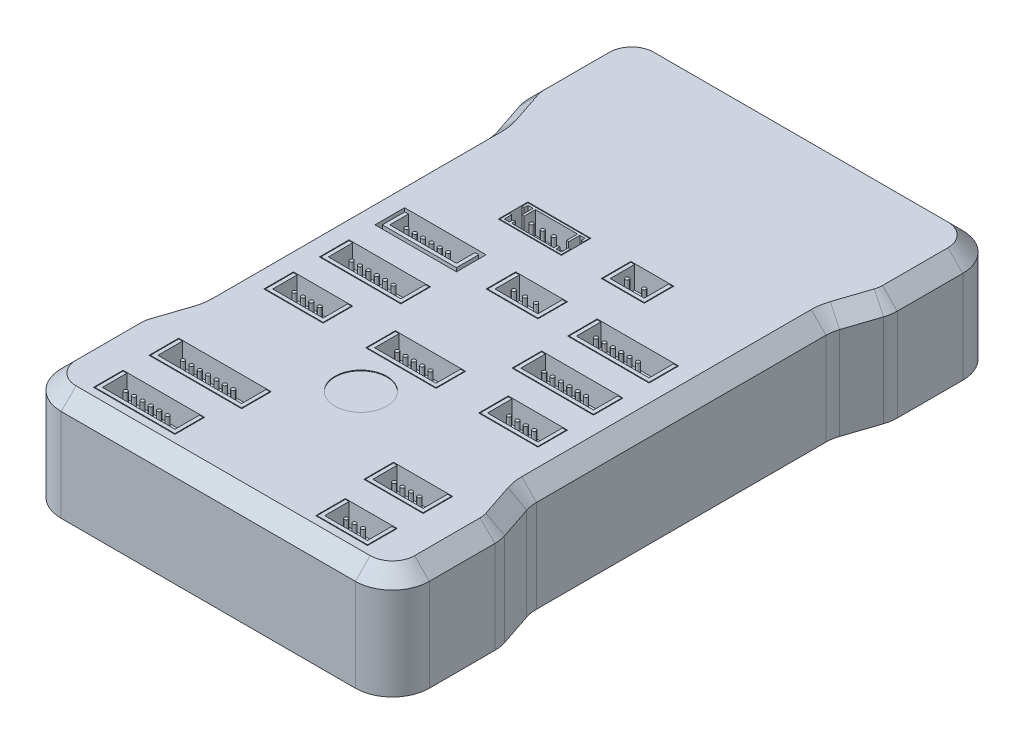
from build123d import *

# Parameters (mm, degrees)
BOSS_EXTRUDE1_DEPTH  = 16
CHAMFER2_SIZE        = 2
CHAMFER3_SIZE        = 3.5
CHAMFER3_SIZE2       = 1.5
CUT_EXTRUDE2_DEPTH   = 0.5
SKETCH5_W            = 8.5
SKETCH5_H            = 4
SKETCH5_W_2          = 5.8
SKETCH5_W_3          = 11
SKETCH5_W_4          = 7
SKETCH5_W_5          = 8
SKETCH5_W_6          = 9.5
SKETCH5_W_7          = 12.5
CUT_EXTRUDE3_DEPTH   = 4
BOSS_EXTRUDE2_DEPTH  = 4
SKETCH7_W            = 8.3
SKETCH7_H            = 3.8
BOSS_EXTRUDE3_DEPTH  = 1
SKETCH8_R            = 0.25
BOSS_EXTRUDE4_DEPTH  = 3
BOSS_EXTRUDE5_DEPTH  = 4
BOSS_EXTRUDE6_DEPTH  = 1
SKETCH11_R           = 0.25
BOSS_EXTRUDE7_DEPTH  = 3
SKETCH12_W           = 10
SKETCH12_H           = 3
BOSS_EXTRUDE8_DEPTH  = 1
BOSS_EXTRUDE9_DEPTH  = 3
SKETCH14_R           = 0.25
BOSS_EXTRUDE10_DEPTH = 3
SKETCH15_W           = 6.8
SKETCH15_H           = 3.8
BOSS_EXTRUDE11_DEPTH = 1
BOSS_EXTRUDE12_DEPTH = 3
SKETCH17_R           = 0.25
BOSS_EXTRUDE13_DEPTH = 3
SKETCH18_W           = 10.8
SKETCH18_H           = 3.8
BOSS_EXTRUDE14_DEPTH = 1
BOSS_EXTRUDE15_DEPTH = 3
SKETCH20_R           = 0.25
SKETCH20_R_2         = 0.247012806
SKETCH20_R_3         = 0.247012796
BOSS_EXTRUDE16_DEPTH = 3
SKETCH22_W           = 10.8
SKETCH22_H           = 3.8
BOSS_EXTRUDE17_DEPTH = 1
BOSS_EXTRUDE18_DEPTH = 3
SKETCH24_R           = 0.25
BOSS_EXTRUDE19_DEPTH = 3
SKETCH25_W           = 10.8
SKETCH25_H           = 3.8
BOSS_EXTRUDE20_DEPTH = 1
BOSS_EXTRUDE21_DEPTH = 3
SKETCH27_R           = 0.25
BOSS_EXTRUDE22_DEPTH = 3
SKETCH28_W           = 7.8
SKETCH28_H           = 3.8
BOSS_EXTRUDE23_DEPTH = 1
BOSS_EXTRUDE24_DEPTH = 3
SKETCH30_R           = 0.25
BOSS_EXTRUDE25_DEPTH = 3
SKETCH31_W           = 9.3
SKETCH31_H           = 3.8
BOSS_EXTRUDE26_DEPTH = 1
BOSS_EXTRUDE27_DEPTH = 3
SKETCH33_R           = 0.25
BOSS_EXTRUDE28_DEPTH = 3
SKETCH34_W           = 7.8
SKETCH34_H           = 3.8
BOSS_EXTRUDE29_DEPTH = 1
BOSS_EXTRUDE30_DEPTH = 3
SKETCH36_R           = 0.25
BOSS_EXTRUDE31_DEPTH = 3
SKETCH37_W           = 12.3
SKETCH37_H           = 3.8
BOSS_EXTRUDE32_DEPTH = 1
BOSS_EXTRUDE33_DEPTH = 3
SKETCH39_R           = 0.25
BOSS_EXTRUDE34_DEPTH = 3
SKETCH40_W           = 7.8
SKETCH40_H           = 3.8
BOSS_EXTRUDE35_DEPTH = 1
BOSS_EXTRUDE36_DEPTH = 3
SKETCH42_R           = 0.25
BOSS_EXTRUDE37_DEPTH = 3
SKETCH43_W           = 10.8
SKETCH43_H           = 3.8
BOSS_EXTRUDE38_DEPTH = 1
BOSS_EXTRUDE39_DEPTH = 3
SKETCH45_R           = 0.25
BOSS_EXTRUDE40_DEPTH = 3
SKETCH46_W           = 6.8
SKETCH46_H           = 3.8
BOSS_EXTRUDE41_DEPTH = 1
BOSS_EXTRUDE42_DEPTH = 3
SKETCH48_R           = 0.25
BOSS_EXTRUDE43_DEPTH = 3
SKETCH49_R           = 3.5
CUT_EXTRUDE4_DEPTH   = 0.1
SKETCH51_W           = 39.7
SKETCH51_H           = 9
CUT_EXTRUDE5_DEPTH   = 7
SKETCH52_R           = 0.25
BOSS_EXTRUDE46_DEPTH = 7


with BuildPart() as part:
    # Sketch1 → Boss-Extrude1 (new body)
    with BuildSketch(Plane(origin=(0, 0, 0), x_dir=(1, 0, 0), z_dir=(0, 1, 0))):
        with BuildLine():
            Line((-19.85, 41), (19.85, 41))
            ThreePointArc((19.85, 41), (23.385533906, 39.535533906), (24.85, 36))
            Line((24.85, 36), (24.85, 27.161388301))
            ThreePointArc((24.85, 27.161388301), (24.785437288, 26.360477086), (24.59341649, 25.580249471))
            Line((24.59341649, 25.580249471), (23.10658351, 21.119750529))
            ThreePointArc((23.10658351, 21.119750529), (22.914562712, 20.339522914), (22.85, 19.538611699))
            Line((22.85, 19.538611699), (22.85, -19.538611699))
            ThreePointArc((22.85, -19.538611699), (22.914562712, -20.339522914), (23.10658351, -21.119750529))
            Line((23.10658351, -21.119750529), (24.59341649, -25.580249471))
            ThreePointArc((24.59341649, -25.580249471), (24.785437288, -26.360477086), (24.85, -27.161388301))
            Line((24.85, -27.161388301), (24.85, -36))
            ThreePointArc((24.85, -36), (23.385533906, -39.535533906), (19.85, -41))
            Line((19.85, -41), (-19.85, -41))
            ThreePointArc((-19.85, -41), (-23.385533906, -39.535533906), (-24.85, -36))
            Line((-24.85, -36), (-24.85, -27.161388301))
            ThreePointArc((-24.85, -27.161388301), (-24.785437288, -26.360477086), (-24.59341649, -25.580249471))
            Line((-24.59341649, -25.580249471), (-23.10658351, -21.119750529))
            ThreePointArc((-23.10658351, -21.119750529), (-22.914562712, -20.339522914), (-22.85, -19.538611699))
            Line((-22.85, -19.538611699), (-22.85, 19.538611699))
            ThreePointArc((-22.85, 19.538611699), (-22.914562712, 20.339522914), (-23.10658351, 21.119750529))
            Line((-23.10658351, 21.119750529), (-24.59341649, 25.580249471))
            ThreePointArc((-24.59341649, 25.580249471), (-24.785437288, 26.360477086), (-24.85, 27.161388301))
            Line((-24.85, 27.161388301), (-24.85, 36))
            ThreePointArc((-24.85, 36), (-23.385533906, 39.535533906), (-19.85, 41))
        make_face()
    extrude(amount=BOSS_EXTRUDE1_DEPTH)

    # Chamfer2
    chamfer2_edges = [part.edges().sort_by_distance(p)[0] for p in [
        (22.914562712, 16, 20.339522914),
        (22.85, 16, 0),
        (23.85, 16, 23.35),
        (22.914562712, 16, -20.339522914),
        (24.785437288, 16, 26.360477086),
        (23.85, 16, -23.35),
        (24.85, 16, 31.58069415),
        (24.785437288, 16, -26.360477086),
        (23.385533906, 16, 39.535533906),
        (24.85, 16, -31.58069415),
        (0, 16, 41),
        (23.385533906, 16, -39.535533906),
        (-23.385533906, 16, 39.535533906),
        (0, 16, -41),
        (-24.85, 16, 31.58069415),
        (-23.385533906, 16, -39.535533906),
        (-24.785437288, 16, 26.360477086),
        (-24.85, 16, -31.58069415),
        (-23.85, 16, 23.35),
        (-24.785437288, 16, -26.360477086),
        (-22.914562712, 16, 20.339522914),
        (-23.85, 16, -23.35),
        (-22.85, 16, 0),
        (-22.914562712, 16, -20.339522914),
    ]]
    chamfer(chamfer2_edges, length=CHAMFER2_SIZE)

    # Chamfer3
    chamfer3_edges = [part.edges().sort_by_distance(p)[0] for p in [
        (24.85, 0, -31.58069415),
        (24.785437288, 0, -26.360477086),
        (23.85, 0, -23.35),
        (22.914562712, 0, -20.339522914),
        (22.85, 0, 0),
        (22.914562712, 0, 20.339522914),
        (23.85, 0, 23.35),
        (24.785437288, 0, 26.360477086),
        (24.85, 0, 31.58069415),
        (23.385533906, 0, 39.535533906),
        (0, 0, 41),
        (-23.385533906, 0, 39.535533906),
        (-24.85, 0, 31.58069415),
        (-24.785437288, 0, 26.360477086),
        (-23.85, 0, 23.35),
        (-22.914562712, 0, 20.339522914),
        (-22.85, 0, 0),
        (-22.914562712, 0, -20.339522914),
        (-23.85, 0, -23.35),
        (-24.785437288, 0, -26.360477086),
        (-24.85, 0, -31.58069415),
        (-23.385533906, 0, -39.535533906),
        (0, 0, -41),
        (23.385533906, 0, -39.535533906),
    ]]
    chamfer3_side = [part.faces().sort_by_distance(p)[0] for p in [
        (0, 0, 0),
    ]]
    chamfer(chamfer3_edges, length=CHAMFER3_SIZE, length2=CHAMFER3_SIZE2, reference=chamfer3_side[0])

    # Sketch4 → Cut-Extrude2 (cut)
    with BuildSketch(Plane.XZ):
        with BuildLine():
            Line((-18.35, 36.5), (-12.35, 36.5))
            ThreePointArc((-12.35, 36.5), (-10.935786438, 35.914213562), (-10.35, 34.5))
            Line((-10.35, 34.5), (-10.35, 28.5))
            ThreePointArc((-10.35, 28.5), (-10.935786438, 27.085786438), (-12.35, 26.5))
            Line((-12.35, 26.5), (-18.35, 26.5))
            ThreePointArc((-18.35, 26.5), (-19.764213562, 27.085786438), (-20.35, 28.5))
            Line((-20.35, 28.5), (-20.35, 34.5))
            ThreePointArc((-20.35, 34.5), (-19.764213562, 35.914213562), (-18.35, 36.5))
        make_face()
        with BuildLine():
            Line((18.35, 26.5), (12.35, 26.5))
            ThreePointArc((12.35, 26.5), (10.935786438, 27.085786438), (10.35, 28.5))
            Line((10.35, 28.5), (10.35, 34.5))
            ThreePointArc((10.35, 34.5), (10.935786438, 35.914213562), (12.35, 36.5))
            Line((12.35, 36.5), (18.35, 36.5))
            ThreePointArc((18.35, 36.5), (19.764213562, 35.914213562), (20.35, 34.5))
            Line((20.35, 34.5), (20.35, 28.5))
            ThreePointArc((20.35, 28.5), (19.764213562, 27.085786438), (18.35, 26.5))
        make_face()
        with BuildLine():
            Line((20.35, -34.5), (20.35, -28.5))
            ThreePointArc((20.35, -28.5), (19.764213562, -27.085786438), (18.35, -26.5))
            Line((18.35, -26.5), (12.35, -26.5))
            ThreePointArc((12.35, -26.5), (10.935786438, -27.085786438), (10.35, -28.5))
            Line((10.35, -28.5), (10.35, -34.5))
            ThreePointArc((10.35, -34.5), (10.935786438, -35.914213562), (12.35, -36.5))
            Line((12.35, -36.5), (18.35, -36.5))
            ThreePointArc((18.35, -36.5), (19.764213562, -35.914213562), (20.35, -34.5))
        make_face()
        with BuildLine():
            Line((-18.35, -26.5), (-12.35, -26.5))
            ThreePointArc((-12.35, -26.5), (-10.935786438, -27.085786438), (-10.35, -28.5))
            Line((-10.35, -28.5), (-10.35, -34.5))
            ThreePointArc((-10.35, -34.5), (-10.935786438, -35.914213562), (-12.35, -36.5))
            Line((-12.35, -36.5), (-18.35, -36.5))
            ThreePointArc((-18.35, -36.5), (-19.764213562, -35.914213562), (-20.35, -34.5))
            Line((-20.35, -34.5), (-20.35, -28.5))
            ThreePointArc((-20.35, -28.5), (-19.764213562, -27.085786438), (-18.35, -26.5))
        make_face()
        with BuildLine():
            Line((-10.75, 17.75), (10.75, 17.75))
            ThreePointArc((10.75, 17.75), (12.164213562, 17.164213562), (12.75, 15.75))
            Line((12.75, 15.75), (12.75, -15.75))
            ThreePointArc((12.75, -15.75), (12.164213562, -17.164213562), (10.75, -17.75))
            Line((10.75, -17.75), (-10.75, -17.75))
            ThreePointArc((-10.75, -17.75), (-12.164213562, -17.164213562), (-12.75, -15.75))
            Line((-12.75, -15.75), (-12.75, 15.75))
            ThreePointArc((-12.75, 15.75), (-12.164213562, 17.164213562), (-10.75, 17.75))
        make_face()
    extrude(amount=-CUT_EXTRUDE2_DEPTH, mode=Mode.SUBTRACT)

    # Sketch5 → Cut-Extrude3 (cut)
    with BuildSketch(Plane(origin=(0, 16, 0), x_dir=(1, 0, 0), z_dir=(0, 1, 0))):
        with Locations((-6.6, 11)):
            Rectangle(SKETCH5_W, SKETCH5_H)
        with Locations((5.95, 11)):
            Rectangle(SKETCH5_W_2, SKETCH5_H)
        with Locations((-13, -5.5)):
            Rectangle(SKETCH5_W_3, SKETCH5_H)
        with Locations((-13, 2)):
            Rectangle(SKETCH5_W_3, SKETCH5_H)
        with Locations((0, 2)):
            Rectangle(SKETCH5_W_4, SKETCH5_H)
        with Locations((13, 2)):
            Rectangle(SKETCH5_W_3, SKETCH5_H)
        with Locations((13, -5.5)):
            Rectangle(SKETCH5_W_3, SKETCH5_H)
        with Locations((-14.5, -13)):
            Rectangle(SKETCH5_W_5, SKETCH5_H)
        with Locations((0, -13)):
            Rectangle(SKETCH5_W_6, SKETCH5_H)
        with Locations((14.5, -13)):
            Rectangle(SKETCH5_W_5, SKETCH5_H)
        with Locations((-13, -36)):
            Rectangle(SKETCH5_W_3, SKETCH5_H)
        with Locations((-12.25, -28.5)):
            Rectangle(SKETCH5_W_7, SKETCH5_H)
        with Locations((14.5, -28.5)):
            Rectangle(SKETCH5_W_5, SKETCH5_H)
        with Locations((15, -36)):
            Rectangle(SKETCH5_W_4, SKETCH5_H)
    extrude(amount=-CUT_EXTRUDE3_DEPTH, mode=Mode.SUBTRACT)

    # Sketch6 → Boss-Extrude2 (add)
    with BuildSketch(Plane(origin=(0, 12, 0), x_dir=(1, 0, 0), z_dir=(0, 1, 0))):
        Polygon((-9.75, 11.1), (-9.45, 11.1), (-9.45, 12.6), (-3.75, 12.6), (-3.75, 11.1), (-3.45, 11.1), (-3.45, 12.6), (-2.75, 12.6), (-2.75, 12.1), (-2.45, 12.1), (-2.45, 12.9), (-10.75, 12.9), (-10.75, 12.1), (-10.45, 12.1), (-10.45, 12.6), (-9.75, 12.6), align=None)
        Polygon((-3.45, 9.4), (-2.75, 9.4), (-2.75, 10.4), (-2.45, 10.4), (-2.45, 9.1), (-10.75, 9.1), (-10.75, 10.4), (-10.45, 10.4), (-10.45, 9.4), (-9.75, 9.4), (-9.75, 9.9), (-9.45, 9.9), (-9.45, 9.4), (-3.75, 9.4), (-3.75, 9.9), (-3.45, 9.9), align=None)
    extrude(amount=BOSS_EXTRUDE2_DEPTH)

    # Sketch7 → Boss-Extrude3 (add)
    with BuildSketch(Plane(origin=(0, 12, 0), x_dir=(1, 0, 0), z_dir=(0, 1, 0))):
        with Locations((-6.6, 11)):
            Rectangle(SKETCH7_W, SKETCH7_H)
    extrude(amount=BOSS_EXTRUDE3_DEPTH)

    # Sketch8 → Boss-Extrude4 (add)
    with BuildSketch(Plane(origin=(0, 13, 0), x_dir=(1, 0, 0), z_dir=(0, 1, 0))):
        with Locations((-6.6, 10.75)):
            Circle(SKETCH8_R)
        with Locations((-5.1, 10.75)):
            Circle(SKETCH8_R)
        with Locations((-8.1, 10.75)):
            Circle(SKETCH8_R)
    extrude(amount=BOSS_EXTRUDE4_DEPTH)

    # Sketch9 → Boss-Extrude5 (add)
    with BuildSketch(Plane(origin=(0, 12, 0), x_dir=(1, 0, 0), z_dir=(0, 1, 0))):
        Polygon((8.75, 12.9), (8.25, 12.9), (8.25, 9.6), (3.65, 9.6), (3.65, 12.9), (3.15, 12.9), (3.15, 9.1), (8.75, 9.1), align=None)
    extrude(amount=BOSS_EXTRUDE5_DEPTH)

    # Sketch10 → Boss-Extrude6 (add)
    with BuildSketch(Plane(origin=(0, 12, 0), x_dir=(1, 0, 0), z_dir=(0, 1, 0))):
        Polygon((8.75, 12.9), (8.75, 9.1), (3.15, 9.1), (3.15, 12.9), (3.65, 12.9), align=None)
    extrude(amount=BOSS_EXTRUDE6_DEPTH)

    # Sketch11 → Boss-Extrude7 (add)
    with BuildSketch(Plane(origin=(0, 13, 0), x_dir=(1, 0, 0), z_dir=(0, 1, 0))):
        with Locations((4.8, 10.75)):
            Circle(SKETCH11_R)
        with Locations((7.1, 10.75)):
            Circle(SKETCH11_R)
    extrude(amount=BOSS_EXTRUDE7_DEPTH)

    # Sketch12 → Boss-Extrude8 (add)
    with BuildSketch(Plane(origin=(0, 12, 0), x_dir=(1, 0, 0), z_dir=(0, 1, 0))):
        with Locations((-13, 2)):
            Rectangle(SKETCH12_W, SKETCH12_H)
    extrude(amount=BOSS_EXTRUDE8_DEPTH)

    # Sketch13 → Boss-Extrude9 (add)
    with BuildSketch(Plane(origin=(0, 13, 0), x_dir=(1, 0, 0), z_dir=(0, 1, 0))):
        Polygon((-18, 3.5), (-18, 0.5), (-8, 0.5), (-8, 3.5), (-8.5, 3.5), (-8.5, 1), (-17.5, 1), (-17.5, 3.5), align=None)
    extrude(amount=BOSS_EXTRUDE9_DEPTH)

    # Sketch14 → Boss-Extrude10 (add)
    with BuildSketch(Plane(origin=(0, 13, 0), x_dir=(1, 0, 0), z_dir=(0, 1, 0))):
        with Locations((-16, 1.75)):
            Circle(SKETCH14_R)
        with Locations((-14.875, 1.75)):
            Circle(SKETCH14_R)
        with Locations((-13.75, 1.75)):
            Circle(SKETCH14_R)
        with Locations((-12.625, 1.75)):
            Circle(SKETCH14_R)
        with Locations((-11.5, 1.75)):
            Circle(SKETCH14_R)
        with Locations((-10.375, 1.75)):
            Circle(SKETCH14_R)
    extrude(amount=BOSS_EXTRUDE10_DEPTH)

    # Sketch15 → Boss-Extrude11 (add)
    with BuildSketch(Plane(origin=(0, 12, 0), x_dir=(1, 0, 0), z_dir=(0, 1, 0))):
        with Locations((0, 2)):
            Rectangle(SKETCH15_W, SKETCH15_H)
    extrude(amount=BOSS_EXTRUDE11_DEPTH)

    # Sketch16 → Boss-Extrude12 (add)
    with BuildSketch(Plane(origin=(0, 13, 0), x_dir=(1, 0, 0), z_dir=(0, 1, 0))):
        Polygon((-3.4, 0.1), (-3.4, 3.9), (-2.9, 3.9), (-2.9, 0.6), (2.9, 0.6), (2.9, 3.9), (3.4, 3.9), (3.4, 0.1), align=None)
    extrude(amount=BOSS_EXTRUDE12_DEPTH)

    # Sketch17 → Boss-Extrude13 (add)
    with BuildSketch(Plane(origin=(0, 13, 0), x_dir=(1, 0, 0), z_dir=(0, 1, 0))):
        with Locations((0, 1.75)):
            Circle(SKETCH17_R)
        with Locations((-1.5, 1.75)):
            Circle(SKETCH17_R)
        with Locations((1.5, 1.75)):
            Circle(SKETCH17_R)
    extrude(amount=BOSS_EXTRUDE13_DEPTH)

    # Sketch18 → Boss-Extrude14 (add)
    with BuildSketch(Plane(origin=(0, 12, 0), x_dir=(1, 0, 0), z_dir=(0, 1, 0))):
        with Locations((13, 2)):
            Rectangle(SKETCH18_W, SKETCH18_H)
    extrude(amount=BOSS_EXTRUDE14_DEPTH)

    # Sketch19 → Boss-Extrude15 (add)
    with BuildSketch(Plane(origin=(0, 13, 0), x_dir=(1, 0, 0), z_dir=(0, 1, 0))):
        Polygon((7.6, 0.1), (7.6, 3.9), (8.1, 3.9), (8.1, 0.6), (17.9, 0.6), (17.9, 3.9), (18.4, 3.9), (18.4, 0.1), align=None)
    extrude(amount=BOSS_EXTRUDE15_DEPTH)

    # Sketch20 → Boss-Extrude16 (add)
    with BuildSketch(Plane(origin=(0, 13, 0), x_dir=(1, 0, 0), z_dir=(0, 1, 0))):
        with Locations((14.122334432, 1.747012796)):
            Circle(SKETCH20_R)
        with Locations((15.252334432, 1.747012796)):
            Circle(SKETCH20_R)
        with Locations((11.862334432, 1.74999999)):
            Circle(SKETCH20_R_2)
        with Locations((10.732338381, 1.747012796)):
            Circle(SKETCH20_R)
        with Locations((12.992334432, 1.75)):
            Circle(SKETCH20_R_3)
        with Locations((9.6, 1.747012796)):
            Circle(SKETCH20_R)
    extrude(amount=BOSS_EXTRUDE16_DEPTH)

    # Sketch22 → Boss-Extrude17 (add)
    with BuildSketch(Plane(origin=(0, 12, 0), x_dir=(1, 0, 0), z_dir=(0, 1, 0))):
        with Locations((-13, -5.5)):
            Rectangle(SKETCH22_W, SKETCH22_H)
    extrude(amount=BOSS_EXTRUDE17_DEPTH)

    # Sketch23 → Boss-Extrude18 (add)
    with BuildSketch(Plane(origin=(0, 13, 0), x_dir=(1, 0, 0), z_dir=(0, 1, 0))):
        Polygon((-18.4, -7.4), (-18.4, -3.6), (-17.9, -3.6), (-17.9, -6.9), (-8.1, -6.9), (-8.1, -3.6), (-7.6, -3.6), (-7.6, -7.4), align=None)
    extrude(amount=BOSS_EXTRUDE18_DEPTH)

    # Sketch24 → Boss-Extrude19 (add)
    with BuildSketch(Plane(origin=(0, 13, 0), x_dir=(1, 0, 0), z_dir=(0, 1, 0))):
        with Locations((-15.9, -5.75)):
            Circle(SKETCH24_R)
        with Locations((-14.77, -5.75)):
            Circle(SKETCH24_R)
        with Locations((-13.64, -5.75)):
            Circle(SKETCH24_R)
        with Locations((-12.51, -5.75)):
            Circle(SKETCH24_R)
        with Locations((-11.38, -5.75)):
            Circle(SKETCH24_R)
        with Locations((-10.25, -5.75)):
            Circle(SKETCH24_R)
    extrude(amount=BOSS_EXTRUDE19_DEPTH)

    # Sketch25 → Boss-Extrude20 (add)
    with BuildSketch(Plane(origin=(0, 12, 0), x_dir=(1, 0, 0), z_dir=(0, 1, 0))):
        with Locations((13, -5.5)):
            Rectangle(SKETCH25_W, SKETCH25_H)
    extrude(amount=BOSS_EXTRUDE20_DEPTH)

    # Sketch26 → Boss-Extrude21 (add)
    with BuildSketch(Plane(origin=(0, 13, 0), x_dir=(1, 0, 0), z_dir=(0, 1, 0))):
        Polygon((7.6, -3.6), (7.6, -7.4), (18.4, -7.4), (18.4, -3.6), (17.9, -3.6), (17.9, -6.9), (8.1, -6.9), (8.1, -3.6), align=None)
    extrude(amount=BOSS_EXTRUDE21_DEPTH)

    # Sketch27 → Boss-Extrude22 (add)
    with BuildSketch(Plane(origin=(0, 13, 0), x_dir=(1, 0, 0), z_dir=(0, 1, 0))):
        with Locations((10.1, -5.75)):
            Circle(SKETCH27_R)
        with Locations((11.23, -5.75)):
            Circle(SKETCH27_R)
        with Locations((12.36, -5.75)):
            Circle(SKETCH27_R)
        with Locations((13.49, -5.75)):
            Circle(SKETCH27_R)
        with Locations((14.62, -5.75)):
            Circle(SKETCH27_R)
        with Locations((15.75, -5.75)):
            Circle(SKETCH27_R)
    extrude(amount=BOSS_EXTRUDE22_DEPTH)

    # Sketch28 → Boss-Extrude23 (add)
    with BuildSketch(Plane(origin=(0, 12, 0), x_dir=(1, 0, 0), z_dir=(0, 1, 0))):
        with Locations((-14.5, -13)):
            Rectangle(SKETCH28_W, SKETCH28_H)
    extrude(amount=BOSS_EXTRUDE23_DEPTH)

    # Sketch29 → Boss-Extrude24 (add)
    with BuildSketch(Plane(origin=(0, 13, 0), x_dir=(1, 0, 0), z_dir=(0, 1, 0))):
        Polygon((-18.4, -11.1), (-18.4, -14.9), (-10.6, -14.9), (-10.6, -11.1), (-11.1, -11.1), (-11.1, -14.4), (-17.9, -14.4), (-17.9, -11.1), align=None)
    extrude(amount=BOSS_EXTRUDE24_DEPTH)

    # Sketch30 → Boss-Extrude25 (add)
    with BuildSketch(Plane(origin=(0, 13, 0), x_dir=(1, 0, 0), z_dir=(0, 1, 0))):
        with Locations((-16.1, -13.25)):
            Circle(SKETCH30_R)
        with Locations((-14.97, -13.25)):
            Circle(SKETCH30_R)
        with Locations((-13.84, -13.25)):
            Circle(SKETCH30_R)
        with Locations((-12.71, -13.25)):
            Circle(SKETCH30_R)
    extrude(amount=BOSS_EXTRUDE25_DEPTH)

    # Sketch31 → Boss-Extrude26 (add)
    with BuildSketch(Plane(origin=(0, 12, 0), x_dir=(1, 0, 0), z_dir=(0, 1, 0))):
        with Locations((0, -13)):
            Rectangle(SKETCH31_W, SKETCH31_H)
    extrude(amount=BOSS_EXTRUDE26_DEPTH)

    # Sketch32 → Boss-Extrude27 (add)
    with BuildSketch(Plane(origin=(0, 13, 0), x_dir=(1, 0, 0), z_dir=(0, 1, 0))):
        Polygon((-4.65, -14.9), (-4.65, -11.1), (-4.15, -11.1), (-4.15, -14.4), (4.15, -14.4), (4.15, -11.1), (4.65, -11.1), (4.65, -14.9), align=None)
    extrude(amount=BOSS_EXTRUDE27_DEPTH)

    # Sketch33 → Boss-Extrude28 (add)
    with BuildSketch(Plane(origin=(0, 13, 0), x_dir=(1, 0, 0), z_dir=(0, 1, 0))):
        with Locations((0, -13.25)):
            Circle(SKETCH33_R)
        with Locations((1.13, -13.256476844)):
            Circle(SKETCH33_R)
        with Locations((-1.13, -13.25)):
            Circle(SKETCH33_R)
        with Locations((2.26, -13.262953689)):
            Circle(SKETCH33_R)
        with Locations((-2.26, -13.237046311)):
            Circle(SKETCH33_R)
    extrude(amount=BOSS_EXTRUDE28_DEPTH)

    # Sketch34 → Boss-Extrude29 (add)
    with BuildSketch(Plane(origin=(0, 12, 0), x_dir=(1, 0, 0), z_dir=(0, 1, 0))):
        with Locations((14.5, -13)):
            Rectangle(SKETCH34_W, SKETCH34_H)
    extrude(amount=BOSS_EXTRUDE29_DEPTH)

    # Sketch35 → Boss-Extrude30 (add)
    with BuildSketch(Plane(origin=(0, 13, 0), x_dir=(1, 0, 0), z_dir=(0, 1, 0))):
        Polygon((10.6, -11.1), (10.6, -14.9), (18.4, -14.9), (18.4, -11.1), (17.9, -11.1), (17.9, -14.4), (11.1, -14.4), (11.1, -11.1), align=None)
    extrude(amount=BOSS_EXTRUDE30_DEPTH)

    # Sketch36 → Boss-Extrude31 (add)
    with BuildSketch(Plane(origin=(0, 13, 0), x_dir=(1, 0, 0), z_dir=(0, 1, 0))):
        with Locations((12.85, -13.25)):
            Circle(SKETCH36_R)
        with Locations((13.98, -13.25)):
            Circle(SKETCH36_R)
        with Locations((15.11, -13.25)):
            Circle(SKETCH36_R)
        with Locations((16.24, -13.25)):
            Circle(SKETCH36_R)
    extrude(amount=BOSS_EXTRUDE31_DEPTH)

    # Sketch37 → Boss-Extrude32 (add)
    with BuildSketch(Plane(origin=(0, 12, 0), x_dir=(1, 0, 0), z_dir=(0, 1, 0))):
        with Locations((-12.25, -28.5)):
            Rectangle(SKETCH37_W, SKETCH37_H)
    extrude(amount=BOSS_EXTRUDE32_DEPTH)

    # Sketch38 → Boss-Extrude33 (add)
    with BuildSketch(Plane(origin=(0, 13, 0), x_dir=(1, 0, 0), z_dir=(0, 1, 0))):
        Polygon((-18.4, -26.6), (-18.4, -30.4), (-6.1, -30.4), (-6.1, -26.6), (-6.6, -26.6), (-6.6, -29.9), (-17.9, -29.9), (-17.9, -26.6), align=None)
    extrude(amount=BOSS_EXTRUDE33_DEPTH)

    # Sketch39 → Boss-Extrude34 (add)
    with BuildSketch(Plane(origin=(0, 13, 0), x_dir=(1, 0, 0), z_dir=(0, 1, 0))):
        with Locations((-12.25, -28.77382246)):
            Circle(SKETCH39_R)
        with Locations((-11.12, -28.77382246)):
            Circle(SKETCH39_R)
        with Locations((-14.51, -28.77382246)):
            Circle(SKETCH39_R)
        with Locations((-13.38, -28.77382246)):
            Circle(SKETCH39_R)
        with Locations((-9.99, -28.77382246)):
            Circle(SKETCH39_R)
        with Locations((-8.86, -28.77382246)):
            Circle(SKETCH39_R)
        with Locations((-15.64, -28.77382246)):
            Circle(SKETCH39_R)
    extrude(amount=BOSS_EXTRUDE34_DEPTH)

    # Sketch40 → Boss-Extrude35 (add)
    with BuildSketch(Plane(origin=(0, 12, 0), x_dir=(1, 0, 0), z_dir=(0, 1, 0))):
        with Locations((14.5, -28.5)):
            Rectangle(SKETCH40_W, SKETCH40_H)
    extrude(amount=BOSS_EXTRUDE35_DEPTH)

    # Sketch41 → Boss-Extrude36 (add)
    with BuildSketch(Plane(origin=(0, 13, 0), x_dir=(1, 0, 0), z_dir=(0, 1, 0))):
        Polygon((10.6, -30.4), (10.6, -26.6), (11.1, -26.6), (11.1, -29.9), (17.9, -29.9), (17.9, -26.6), (18.4, -26.6), (18.4, -30.4), align=None)
    extrude(amount=BOSS_EXTRUDE36_DEPTH)

    # Sketch42 → Boss-Extrude37 (add)
    with BuildSketch(Plane(origin=(0, 13, 0), x_dir=(1, 0, 0), z_dir=(0, 1, 0))):
        with Locations((12.85, -28.75)):
            Circle(SKETCH42_R)
        with Locations((13.98, -28.75)):
            Circle(SKETCH42_R)
        with Locations((15.11, -28.75)):
            Circle(SKETCH42_R)
        with Locations((16.24, -28.75)):
            Circle(SKETCH42_R)
    extrude(amount=BOSS_EXTRUDE37_DEPTH)

    # Sketch43 → Boss-Extrude38 (add)
    with BuildSketch(Plane(origin=(0, 12, 0), x_dir=(1, 0, 0), z_dir=(0, 1, 0))):
        with Locations((-13, -36)):
            Rectangle(SKETCH43_W, SKETCH43_H)
    extrude(amount=BOSS_EXTRUDE38_DEPTH)

    # Sketch44 → Boss-Extrude39 (add)
    with BuildSketch(Plane(origin=(0, 13, 0), x_dir=(1, 0, 0), z_dir=(0, 1, 0))):
        Polygon((-18.4, -34.1), (-18.4, -37.9), (-7.6, -37.9), (-7.6, -34.1), (-8.1, -34.1), (-8.1, -37.4), (-17.9, -37.4), (-17.9, -34.1), align=None)
    extrude(amount=BOSS_EXTRUDE39_DEPTH)

    # Sketch45 → Boss-Extrude40 (add)
    with BuildSketch(Plane(origin=(0, 13, 0), x_dir=(1, 0, 0), z_dir=(0, 1, 0))):
        with Locations((-15.9, -36.25)):
            Circle(SKETCH45_R)
        with Locations((-14.77, -36.25)):
            Circle(SKETCH45_R)
        with Locations((-13.64, -36.25)):
            Circle(SKETCH45_R)
        with Locations((-12.51, -36.25)):
            Circle(SKETCH45_R)
        with Locations((-11.38, -36.25)):
            Circle(SKETCH45_R)
        with Locations((-10.25, -36.25)):
            Circle(SKETCH45_R)
    extrude(amount=BOSS_EXTRUDE40_DEPTH)

    # Sketch46 → Boss-Extrude41 (add)
    with BuildSketch(Plane(origin=(0, 12, 0), x_dir=(1, 0, 0), z_dir=(0, 1, 0))):
        with Locations((15, -36)):
            Rectangle(SKETCH46_W, SKETCH46_H)
    extrude(amount=BOSS_EXTRUDE41_DEPTH)

    # Sketch47 → Boss-Extrude42 (add)
    with BuildSketch(Plane(origin=(0, 13, 0), x_dir=(1, 0, 0), z_dir=(0, 1, 0))):
        Polygon((11.6, -34.1), (11.6, -37.9), (18.4, -37.9), (18.4, -34.1), (17.9, -34.1), (17.9, -37.4), (12.1, -37.4), (12.1, -34.1), align=None)
    extrude(amount=BOSS_EXTRUDE42_DEPTH)

    # Sketch48 → Boss-Extrude43 (add)
    with BuildSketch(Plane(origin=(0, 13, 0), x_dir=(1, 0, 0), z_dir=(0, 1, 0))):
        with Locations((13.87, -36.25)):
            Circle(SKETCH48_R)
        with Locations((15, -36.25)):
            Circle(SKETCH48_R)
        with Locations((16.13, -36.25)):
            Circle(SKETCH48_R)
    extrude(amount=BOSS_EXTRUDE43_DEPTH)

    # Sketch49 → Cut-Extrude4 (cut)
    with BuildSketch(Plane(origin=(0, 16, 0), x_dir=(1, 0, 0), z_dir=(0, 1, 0))):
        with Locations((0, -20.4)):
            Circle(SKETCH49_R)
    extrude(amount=-CUT_EXTRUDE4_DEPTH, mode=Mode.SUBTRACT)

    # Sketch51 → Cut-Extrude5 (cut)
    with BuildSketch(Plane(origin=(0, 0, -41), x_dir=(-1, 0, 0), z_dir=(0, 0, -1))):
        with Locations((0, 6)):
            Rectangle(SKETCH51_W, SKETCH51_H)
    extrude(amount=-CUT_EXTRUDE5_DEPTH, mode=Mode.SUBTRACT)

    # Sketch52 → Boss-Extrude46 (add)
    with BuildSketch(Plane(origin=(0, 0, -34), x_dir=(-1, 0, 0), z_dir=(0, 0, -1))):
        with Locations((-18.609375, 9.259375)):
            Circle(SKETCH52_R)
        with Locations((-18.609375, 6)):
            Circle(SKETCH52_R)
        with Locations((-18.609375, 2.740625)):
            Circle(SKETCH52_R)
        with Locations((-16.129375, 9.259375)):
            Circle(SKETCH52_R)
        with Locations((-16.129375, 6)):
            Circle(SKETCH52_R)
        with Locations((-16.129375, 2.740625)):
            Circle(SKETCH52_R)
        with Locations((-13.649375, 2.740625)):
            Circle(SKETCH52_R)
        with Locations((-13.649375, 6)):
            Circle(SKETCH52_R)
        with Locations((-13.649375, 9.259375)):
            Circle(SKETCH52_R)
        with Locations((-11.169375, 9.259375)):
            Circle(SKETCH52_R)
        with Locations((-11.169375, 6)):
            Circle(SKETCH52_R)
        with Locations((-8.689375, 2.740625)):
            Circle(SKETCH52_R)
        with Locations((-6.209375, 2.740625)):
            Circle(SKETCH52_R)
        with Locations((-6.209375, 6)):
            Circle(SKETCH52_R)
        with Locations((-6.209375, 9.259375)):
            Circle(SKETCH52_R)
        with Locations((-3.729375, 9.259375)):
            Circle(SKETCH52_R)
        with Locations((-3.729375, 6)):
            Circle(SKETCH52_R)
        with Locations((-3.729375, 2.740625)):
            Circle(SKETCH52_R)
        with Locations((-1.249375, 2.740625)):
            Circle(SKETCH52_R)
        with Locations((-1.249375, 6)):
            Circle(SKETCH52_R)
        with Locations((-1.249375, 9.259375)):
            Circle(SKETCH52_R)
        with Locations((1.230625, 9.259375)):
            Circle(SKETCH52_R)
        with Locations((1.230625, 6)):
            Circle(SKETCH52_R)
        with Locations((1.230625, 2.740625)):
            Circle(SKETCH52_R)
        with Locations((3.710625, 9.259375)):
            Circle(SKETCH52_R)
        with Locations((3.710625, 2.740625)):
            Circle(SKETCH52_R)
        with Locations((6.190625, 2.740625)):
            Circle(SKETCH52_R)
        with Locations((6.190625, 6)):
            Circle(SKETCH52_R)
        with Locations((6.190625, 9.259375)):
            Circle(SKETCH52_R)
        with Locations((8.670625, 9.259375)):
            Circle(SKETCH52_R)
        with Locations((8.670625, 6)):
            Circle(SKETCH52_R)
        with Locations((8.670625, 2.740625)):
            Circle(SKETCH52_R)
        with Locations((11.150625, 2.740625)):
            Circle(SKETCH52_R)
        with Locations((11.150625, 6)):
            Circle(SKETCH52_R)
        with Locations((11.150625, 9.259375)):
            Circle(SKETCH52_R)
        with Locations((13.630625, 9.259375)):
            Circle(SKETCH52_R)
        with Locations((13.630625, 6)):
            Circle(SKETCH52_R)
        with Locations((13.630625, 2.740625)):
            Circle(SKETCH52_R)
        with Locations((16.110625, 2.740625)):
            Circle(SKETCH52_R)
        with Locations((16.110625, 6)):
            Circle(SKETCH52_R)
        with Locations((16.110625, 9.259375)):
            Circle(SKETCH52_R)
        with Locations((18.590625, 9.259375)):
            Circle(SKETCH52_R)
        with Locations((18.590625, 6)):
            Circle(SKETCH52_R)
        with Locations((18.590625, 2.740625)):
            Circle(SKETCH52_R)
        with Locations((-11.169375, 2.740625)):
            Circle(SKETCH52_R)
        with Locations((-8.689375, 6)):
            Circle(SKETCH52_R)
        with Locations((-8.689375, 9.259375)):
            Circle(SKETCH52_R)
        with Locations((3.710625, 6)):
            Circle(SKETCH52_R)
    extrude(amount=BOSS_EXTRUDE46_DEPTH)


solid = part.part
